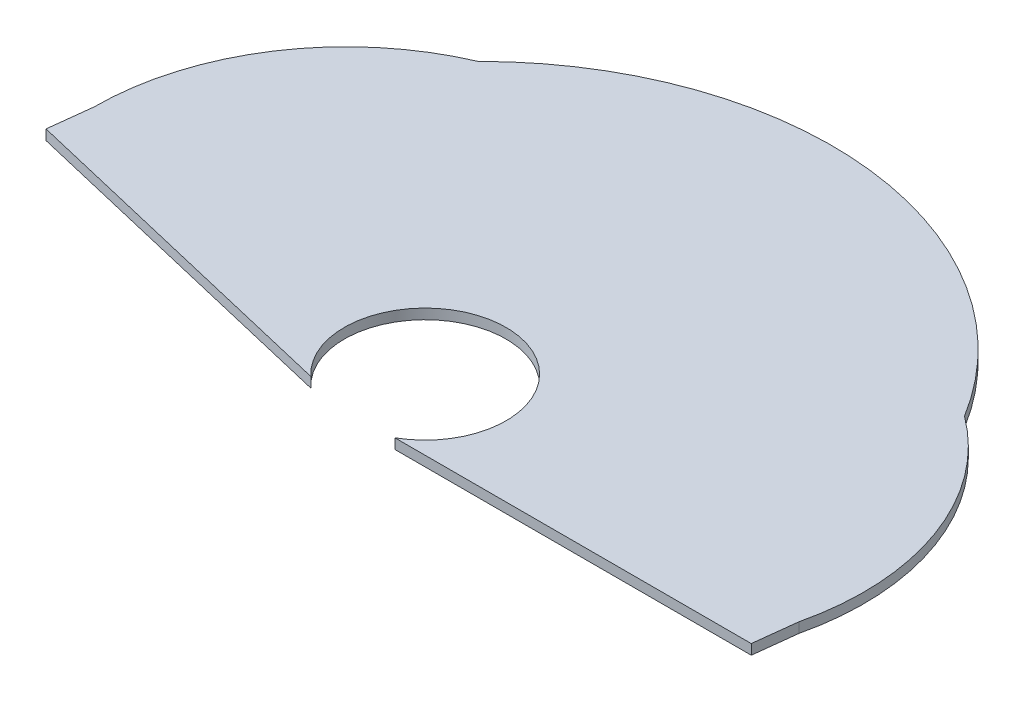
from build123d import *

# Parameters (mm, degrees)
SALIENTE_EXTRUIR2_DEPTH = 0.5
CORTAR_EXTRUIR1_DEPTH   = 0.5
SALIENTE_EXTRUIR3_DEPTH = 0.5


with BuildPart() as part:
    # Croquis2 → Saliente-Extruir2 (new body)
    with BuildSketch(Plane(origin=(0, 0, 0), x_dir=(1, 0, 0), z_dir=(0, 1, 0))):
        with BuildLine():
            Line((0, 0), (20, 0))
            Line((20, 0), (39.463577456, -4.600994744))
            ThreePointArc((39.463577456, -4.600994744), (39.040324802, 2.548287638), (34.753818463, 8.285642846))
            ThreePointArc((34.753818463, 8.285642846), (21.920955681, 16.476389899), (7.548005539, 11.457524625))
            ThreePointArc((7.548005539, 11.457524625), (2.056591074, 6.860161407), (0, 0))
        make_face()
    extrude(amount=SALIENTE_EXTRUIR2_DEPTH)

    # Croquis3 → Cortar-Extruir1 (cut)
    with BuildSketch(Plane(origin=(0, 0.5, 0), x_dir=(1, 0, 0), z_dir=(0, 1, 0))):
        with BuildLine():
            Line((20, 0), (16.5, 0))
            ThreePointArc((16.5, 0), (20.143291885, 1.229040833), (23.406126055, -0.80517408))
            Line((23.406126055, -0.80517408), (20, 0))
        make_face()
    extrude(amount=-CORTAR_EXTRUIR1_DEPTH, mode=Mode.SUBTRACT)

    # Croquis4 → Saliente-Extruir3 (add)
    with BuildSketch(Plane(origin=(0, 0.5, 0), x_dir=(1, 0, 0), z_dir=(0, 1, 0))):
        with BuildLine():
            Line((-0.246717473, -2.116141109), (16.897027571, -6.168750709))
            ThreePointArc((16.897027571, -6.168750709), (18.02539366, 0.426780522), (23.62217394, -3.240683553))
            ThreePointArc((23.62217394, -3.240683553), (23.080050106, -5.251427798), (21.600627731, -6.717135853))
            Line((21.600627731, -6.717135853), (39.216859982, -6.717135853))
            Line((39.216859982, -6.717135853), (39.463577456, -4.600994744))
            Line((39.463577456, -4.600994744), (20.690616261, 2.904236285))
            Line((20.690616261, 2.904236285), (0, 0))
            Line((0, 0), (-0.246717473, -2.116141109))
        make_face()
    extrude(amount=-SALIENTE_EXTRUIR3_DEPTH)


solid = part.part
